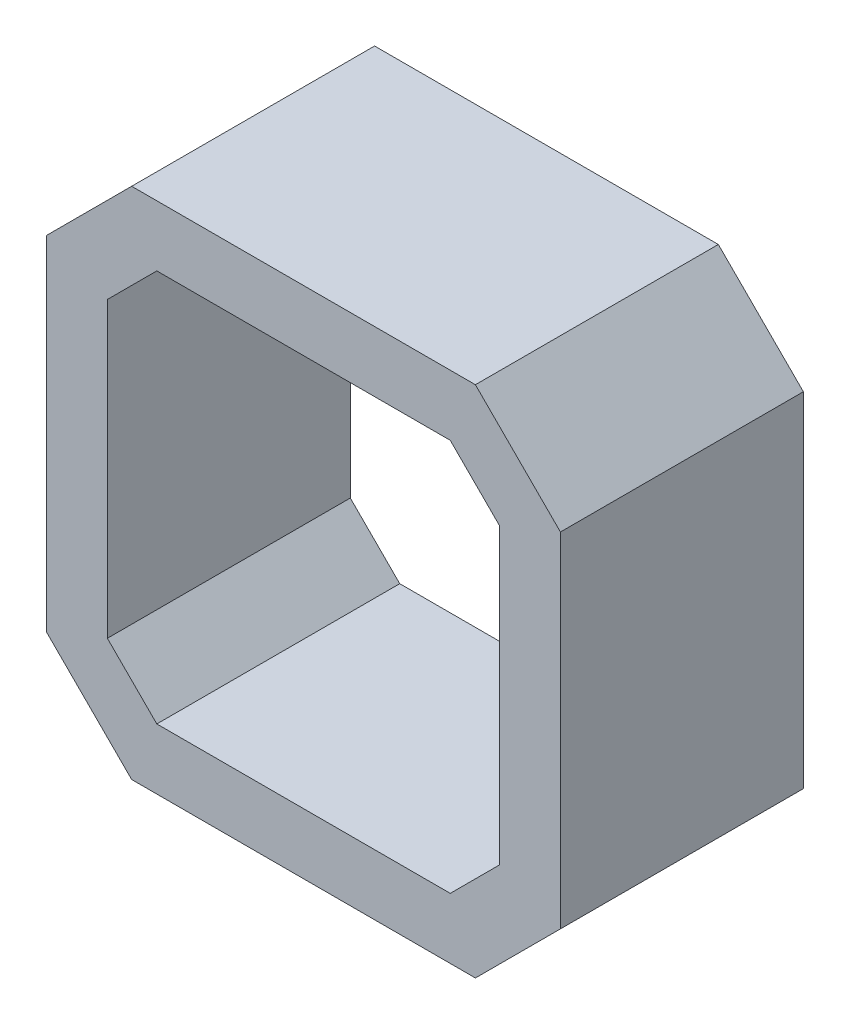
from build123d import *

# Parameters (mm, degrees)
ESTRUSIONE_ESTRUSIONE1_DEPTH = 20


with BuildPart() as part:
    # Schizzo1 → Estrusione-Estrusione1 (new body)
    with BuildSketch(Plane.XY):
        Polygon((-21.15, 14.15), (-14.15, 21.15), (14.15, 21.15), (21.15, 14.15), (21.15, -14.15), (14.15, -21.15), (-14.15, -21.15), (-21.15, -14.15), align=None)
        Polygon((-12.078932188, 16.15), (12.078932188, 16.15), (16.15, 12.078932188), (16.15, -12.078932188), (12.078932188, -16.15), (-12.078932188, -16.15), (-16.15, -12.078932188), (-16.15, 12.078932188), align=None, mode=Mode.SUBTRACT)
    extrude(amount=ESTRUSIONE_ESTRUSIONE1_DEPTH)


solid = part.part
